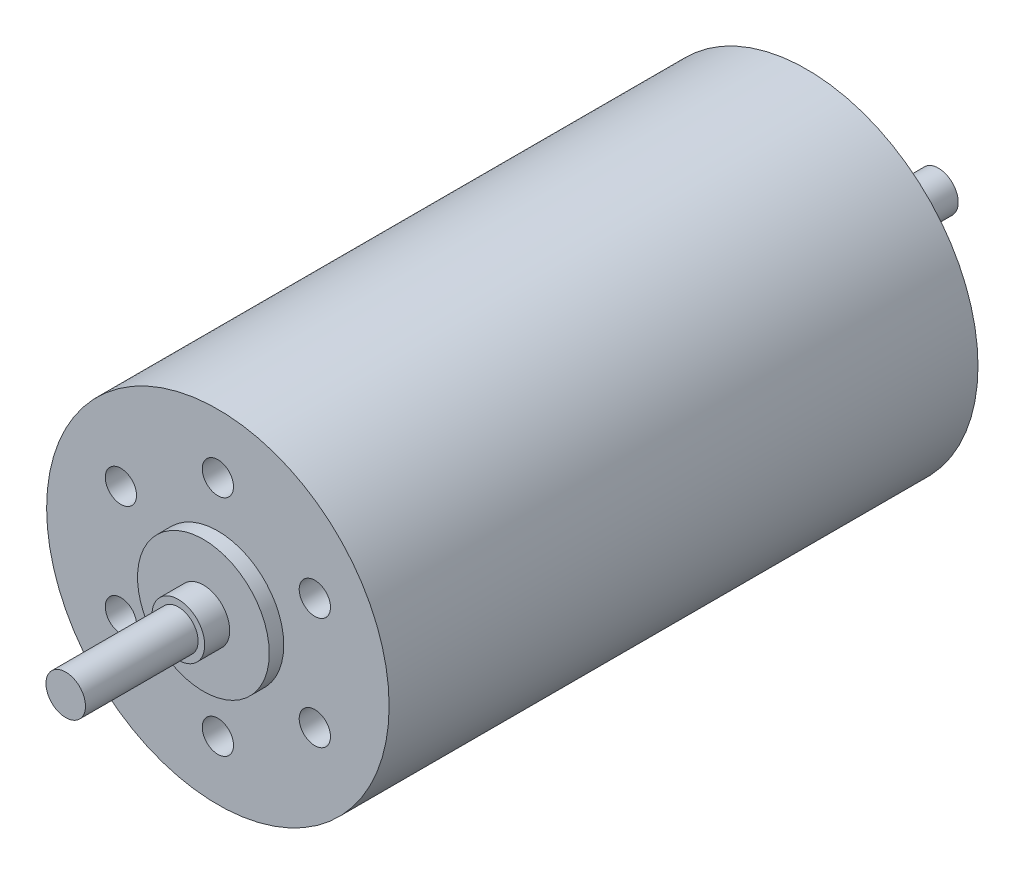
from build123d import *

# Parameters (mm, degrees)
SKETCH1_R                        = 13
BOSS_EXTRUDE1_DEPTH              = 22.35
SKETCH2_R                        = 5
BOSS_EXTRUDE2_DEPTH              = 1.1
SKETCH3_R                        = 2
BOSS_EXTRUDE3_DEPTH              = 1.9
SKETCH4_R                        = 1.5
BOSS_EXTRUDE4_DEPTH              = 8.55
SKETCH5_R                        = 4
BOSS_EXTRUDE5_DEPTH              = 2.2
SKETCH6_R                        = 1.5
BOSS_EXTRUDE6_DEPTH              = 7.8
F_42_0_0935_DIAMETER_HOLE1_D     = 2.3749
F_42_0_0935_DIAMETER_HOLE1_DEPTH = 12.7
F_42_0_0935_DIAMETER_HOLE1_TIP   = 0.713491942


with BuildPart() as part:
    # Sketch1 → Boss-Extrude1 (new body, symmetric)
    with BuildSketch(Plane(origin=(0, 0, 0), x_dir=(0, 1, 0), z_dir=(0, 0, 1))):
        Circle(SKETCH1_R)
    extrude(amount=BOSS_EXTRUDE1_DEPTH, both=True)

    # Sketch2 → Boss-Extrude2 (add)
    with BuildSketch(Plane.XY.offset(22.35)):
        Circle(SKETCH2_R)
    extrude(amount=BOSS_EXTRUDE2_DEPTH)

    # Sketch3 → Boss-Extrude3 (add)
    with BuildSketch(Plane.XY.offset(23.45)):
        Circle(SKETCH3_R)
    extrude(amount=BOSS_EXTRUDE3_DEPTH)

    # Sketch4 → Boss-Extrude4 (add)
    with BuildSketch(Plane.XY.offset(25.35)):
        Circle(SKETCH4_R)
    extrude(amount=BOSS_EXTRUDE4_DEPTH)

    # Sketch5 → Boss-Extrude5 (add)
    with BuildSketch(Plane(origin=(0, 0, -22.35), x_dir=(1, 0, 0), z_dir=(0, 0, -1))):
        Circle(SKETCH5_R)
    extrude(amount=BOSS_EXTRUDE5_DEPTH)

    # Sketch6 → Boss-Extrude6 (add)
    with BuildSketch(Plane(origin=(0, 0, -24.55), x_dir=(1, 0, 0), z_dir=(0, 0, -1))):
        Circle(SKETCH6_R)
    extrude(amount=BOSS_EXTRUDE6_DEPTH)

    # #42 (0.0935) Diameter Hole1
    with Locations(Plane.XY.offset(22.35)):
        with Locations((7.361215932, -4.25), (0, 8.5), (-7.361215932, 4.25), (-7.361215932, -4.25), (7.361215932, 4.25), (0, -8.5)):
            Hole(F_42_0_0935_DIAMETER_HOLE1_D / 2, depth=F_42_0_0935_DIAMETER_HOLE1_DEPTH)
            with Locations((0, 0, -(F_42_0_0935_DIAMETER_HOLE1_DEPTH + F_42_0_0935_DIAMETER_HOLE1_TIP / 2))):  # 118° drill point
                Cone(0, F_42_0_0935_DIAMETER_HOLE1_D / 2, F_42_0_0935_DIAMETER_HOLE1_TIP, mode=Mode.SUBTRACT)


solid = part.part
